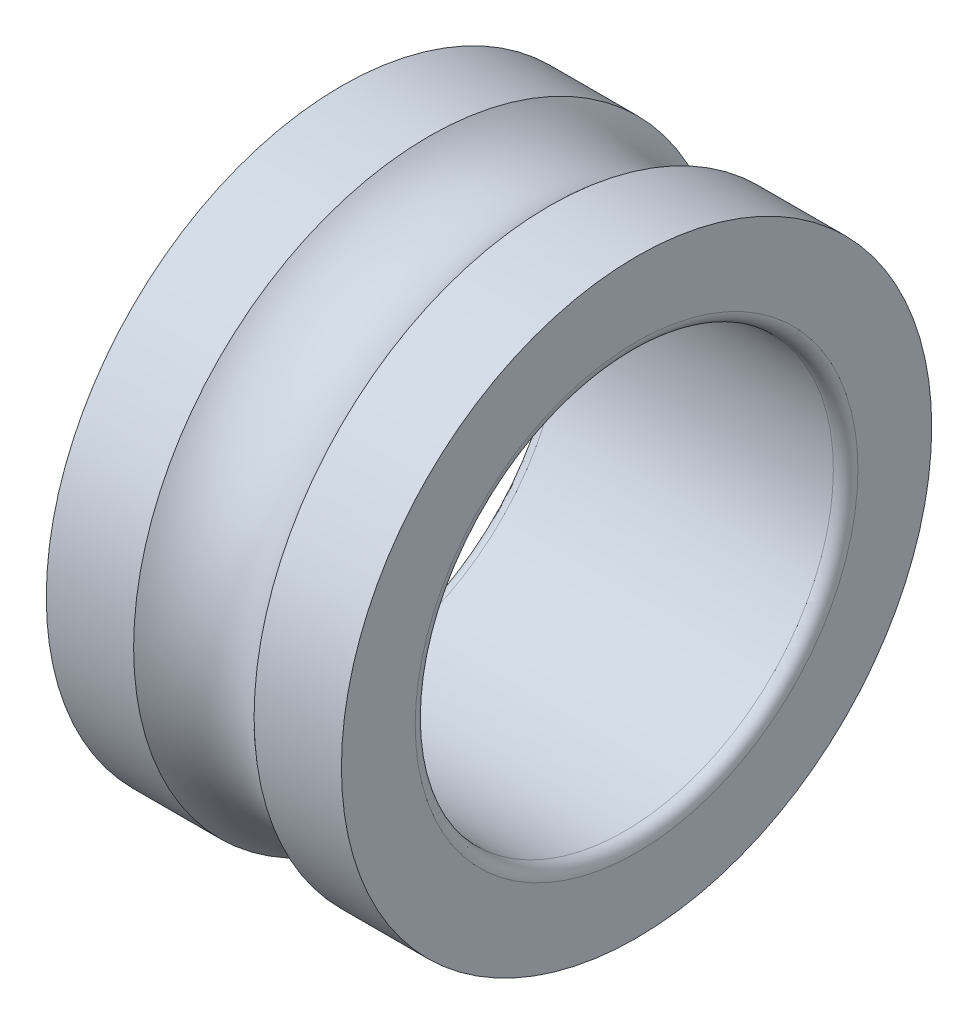
from build123d import *


with BuildPart() as part:
    # Sketch1 → Revolve1 (revolve)
    with BuildSketch(Plane.XY):
        with BuildLine():
            Line((-0.740666673, 8.5), (10.259333327, 8.5))
            ThreePointArc((10.259333327, 8.5), (10.612886718, 8.646446609), (10.759333327, 9))
            Line((10.759333327, 9), (10.759333327, 12))
            Line((10.759333327, 12), (7.20882307, 12))
            ThreePointArc((7.20882307, 12), (4.759333327, 11), (2.309843584, 12))
            Line((2.309843584, 12), (-1.240666673, 12))
            Line((-1.240666673, 12), (-1.240666673, 9))
            ThreePointArc((-1.240666673, 9), (-1.094220063, 8.646446609), (-0.740666673, 8.5))
        make_face()
    revolve(axis=Axis((-52.659695599, 0, 0), (1, 0, 0)))


solid = part.part
